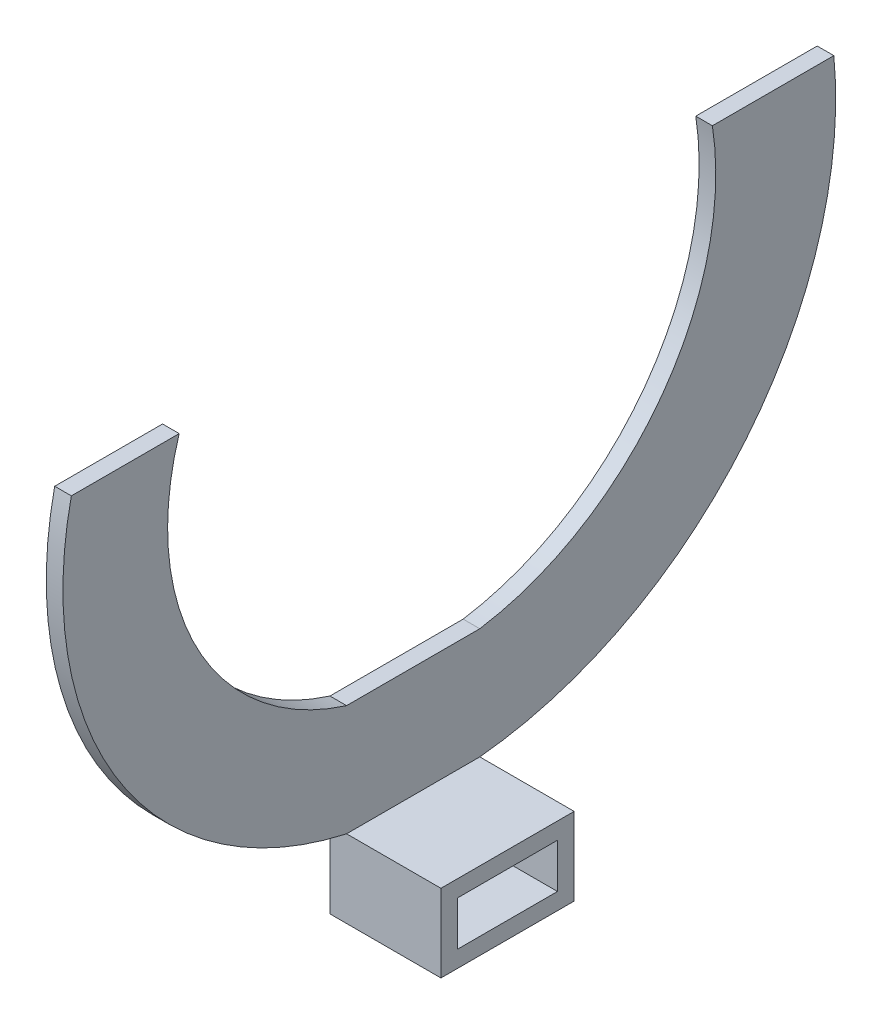
from build123d import *

# Parameters (mm, degrees)
SKETCH1_W           = 24
SKETCH1_H           = 14
SKETCH1_W_2         = 18
SKETCH1_H_2         = 8
BOSS_EXTRUDE1_DEPTH = 20
SKETCH3_W           = 3
SKETCH3_H           = 24
BOSS_EXTRUDE2_DEPTH = 20
BOSS_EXTRUDE4_DEPTH = 3


with BuildPart() as part:
    # Sketch1 → Boss-Extrude1 (new body)
    with BuildSketch(Plane(origin=(0, 0, 0), x_dir=(0, 0, -1), z_dir=(1, 0, 0))):
        with Locations((12, 7)):
            Rectangle(SKETCH1_W, SKETCH1_H)
        with Locations((12, 7)):
            Rectangle(SKETCH1_W_2, SKETCH1_H_2, mode=Mode.SUBTRACT)
    extrude(amount=BOSS_EXTRUDE1_DEPTH)

    # Sketch3 → Boss-Extrude2 (add)
    with BuildSketch(Plane(origin=(0, 14, 0), x_dir=(1, 0, 0), z_dir=(0, 1, 0))):
        with Locations((1.5, 12)):
            Rectangle(SKETCH3_W, SKETCH3_H)
    extrude(amount=BOSS_EXTRUDE2_DEPTH)

    # Sketch5 → Boss-Extrude4 (add)
    with BuildSketch(Plane(origin=(3, 0, 0), x_dir=(0, 0, -1), z_dir=(1, 0, 0))):
        with BuildLine():
            Line((-49.592274582, 91.528999548), (-30.16014503, 91.528999548))
            ThreePointArc((-30.16014503, 91.528999548), (-26.994718436, 56.518129217), (0, 34))
            Line((0, 34), (0, 14))
            ThreePointArc((0, 14), (-40.852918836, 42.493603413), (-49.592274582, 91.528999548))
        make_face()
        with BuildLine():
            Line((65.909693645, 91.528999548), (87.792134304, 91.528999548))
            ThreePointArc((87.792134304, 91.528999548), (71.952848697, 39.552716173), (24, 14))
            Line((24, 14), (24, 34))
            ThreePointArc((24, 34), (56.869492744, 54.084718023), (65.909693645, 91.528999548))
        make_face()
    extrude(amount=-BOSS_EXTRUDE4_DEPTH)


solid = part.part
